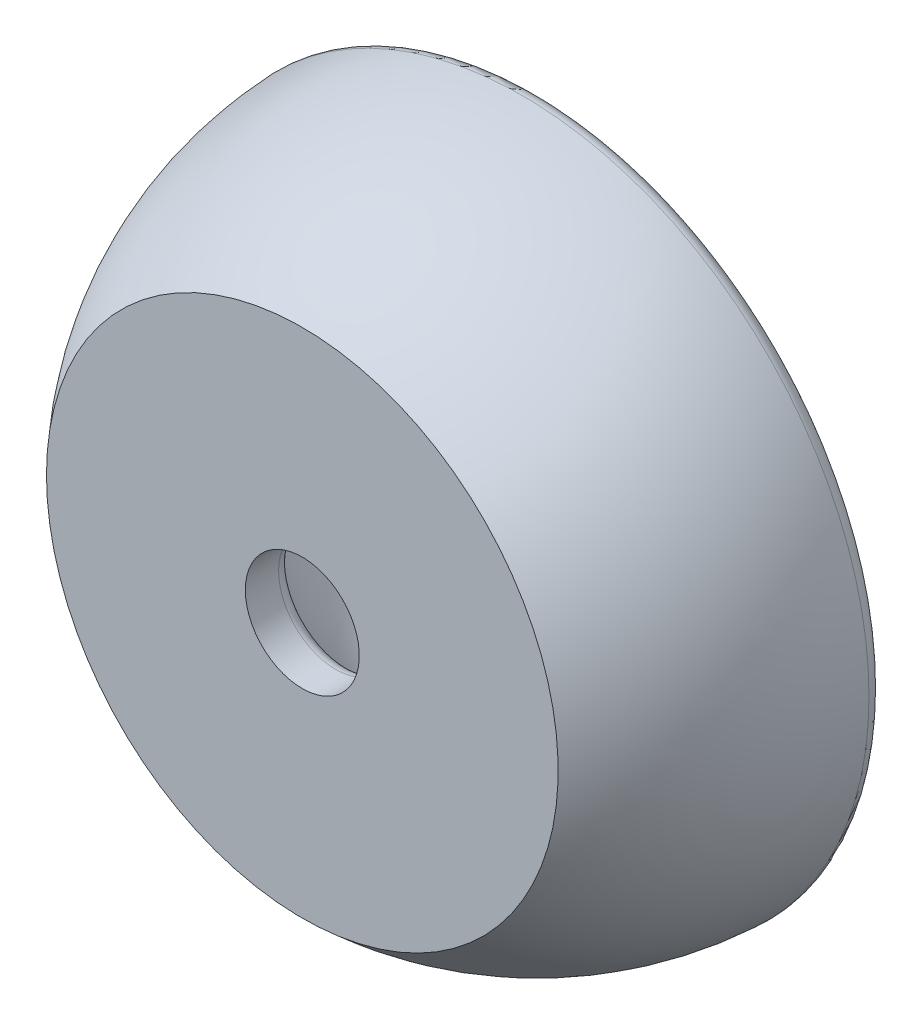
from build123d import *

# Parameters (mm, degrees)
BOTTOM_FILLET_R      = 0.4
CENTER_HOLE_FILLET_R = 0.4


with BuildPart() as part:
    # Sketch2 → Main Body (revolve)
    with BuildSketch(Plane(origin=(0, 0, 0), x_dir=(1, 0, 0), z_dir=(0, 1, 0))):
        with BuildLine():
            Line((5.6, 0), (9.75, 0))
            ThreePointArc((9.75, 0), (9.086189349, -3.536051911), (7.185146027, -6.590612761))
            Line((7.185146027, -6.590612761), (1.6, -6.590612761))
            Line((1.6, -6.590612761), (1.6, -5.366563146))
            ThreePointArc((1.6, -5.366563146), (4.489988864, -3.346640106), (5.6, 0))
        make_face()
    revolve(axis=Axis((0, 0, 0), (0, 0, 1)))

    # Bottom Fillet
    bottom_fillet_edges = [part.edges().sort_by_distance(p)[0] for p in [
        (-5.6, 0, 0),
        (-9.75, 0, 0),
    ]]
    fillet(bottom_fillet_edges, radius=BOTTOM_FILLET_R)

    # Center Hole Fillet
    center_hole_fillet_edges = [part.edges().sort_by_distance(p)[0] for p in [
        (-1.6, 0, 5.366563146),
    ]]
    fillet(center_hole_fillet_edges, radius=CENTER_HOLE_FILLET_R)


solid = part.part
